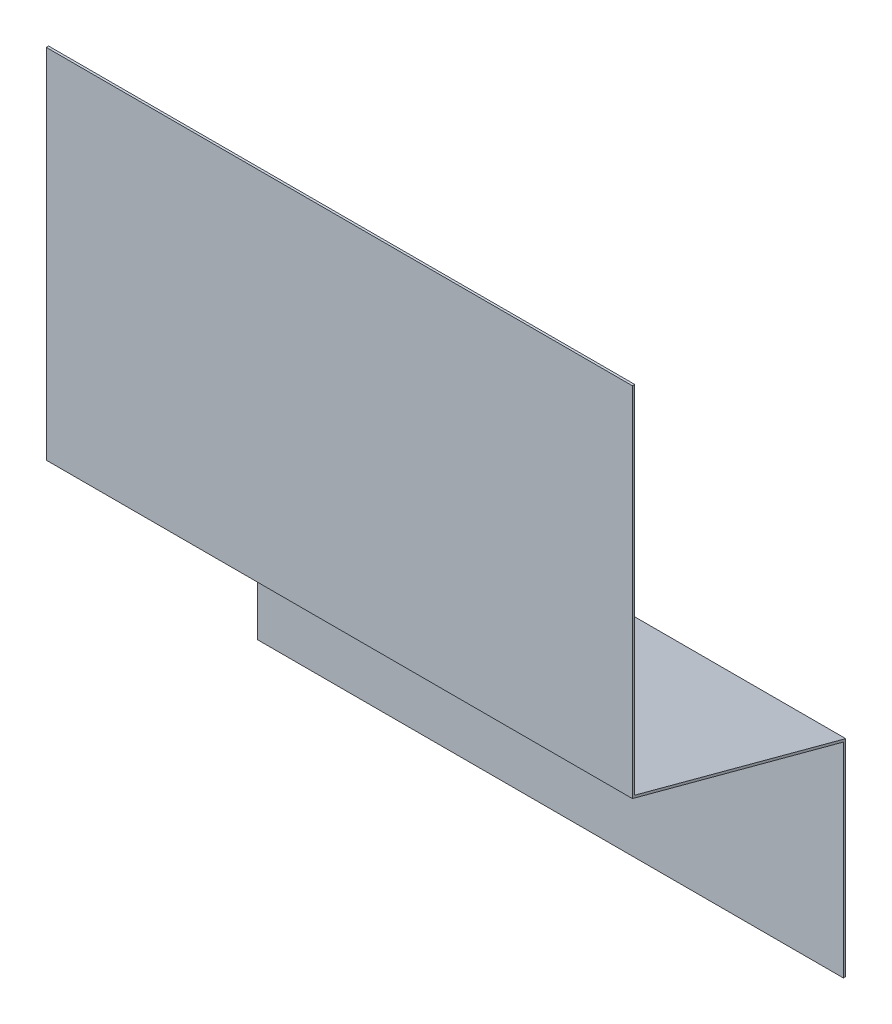
from build123d import *

# Parameters (mm, degrees)
EXTRUDE_THIN1_DEPTH = 397.256


with BuildPart() as part:
    # Sketch1 → Extrude-Thin1 (new body)
    with BuildSketch(Plane(origin=(0, 0, 0), x_dir=(0, 0, -1), z_dir=(1, 0, 0))):
        Polygon((0, 0), (0, 139.7), (-143.002, 178.017270416), (-143.002, 419.1), (-144.5895, 419.1), (-144.5895, 176.799138823), (-1.5875, 138.481868407), (-1.5875, 0), align=None)
    extrude(amount=EXTRUDE_THIN1_DEPTH)


solid = part.part
